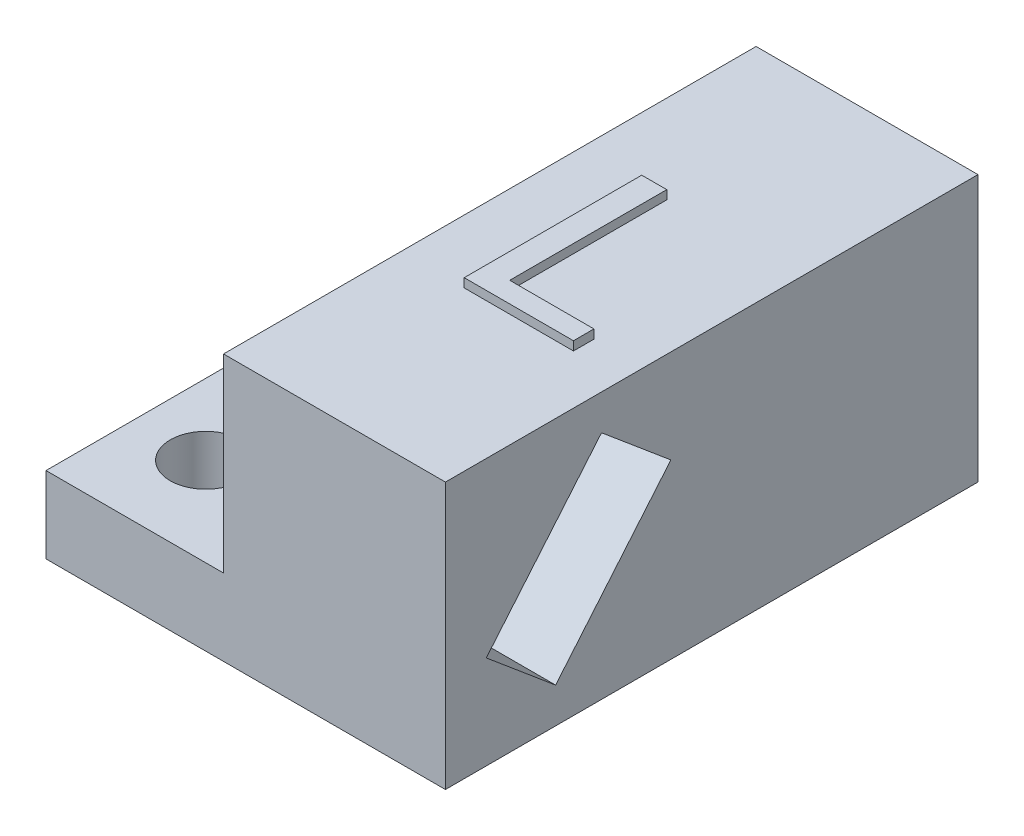
from build123d import *

# Parameters (mm, degrees)
SKETCH1_W           = 25
SKETCH1_H           = 60
BOSS_EXTRUDE1_DEPTH = 30
SKETCH2_W           = 60
SKETCH2_H           = 8.623813306
BOSS_EXTRUDE2_DEPTH = 20
SKETCH3_R           = 4
CUT_EXTRUDE1_DEPTH  = 9.623813306
CUT_EXTRUDE2_DEPTH  = 20
BOSS_EXTRUDE3_DEPTH = 1


with BuildPart() as part:
    # Sketch1 → Boss-Extrude1 (new body)
    with BuildSketch(Plane(origin=(0, 0, 0), x_dir=(1, 0, 0), z_dir=(0, 1, 0))):
        Rectangle(SKETCH1_W, SKETCH1_H)
    extrude(amount=BOSS_EXTRUDE1_DEPTH)

    # Sketch2 → Boss-Extrude2 (add)
    with BuildSketch(Plane.ZY.offset(12.5)):
        with Locations((0, 4.311906653)):
            Rectangle(SKETCH2_W, SKETCH2_H)
    extrude(amount=BOSS_EXTRUDE2_DEPTH)

    # Sketch3 → Cut-Extrude1 (cut, through all)
    with BuildSketch(Plane(origin=(0, 8.623813306, 0), x_dir=(1, 0, 0), z_dir=(0, 1, 0))):
        with Locations(Location((-24.5, 20, 0), (0, 0, 270))):  # turned: the seam where the file's is
            Circle(SKETCH3_R)
        with Locations(Location((-24.5, -20, 0), (0, 0, 270))):  # turned: the seam where the file's is
            Circle(SKETCH3_R)
    extrude(amount=-CUT_EXTRUDE1_DEPTH, mode=Mode.SUBTRACT)

    # Sketch4 → Cut-Extrude2 (cut)
    with BuildSketch(Plane(origin=(12.5, 0, 0), x_dir=(0, 0, -1), z_dir=(1, 0, 0))):
        Polygon((-17.585328198, 3.984734315), (-4.601018482, 19.458832066), (-12.414671802, 26.015265685), (-25.398981518, 10.541167934), align=None)
    extrude(amount=-CUT_EXTRUDE2_DEPTH, mode=Mode.SUBTRACT)

    # Sketch5 → Boss-Extrude3 (add)
    with BuildSketch(Plane(origin=(0, 30, 0), x_dir=(1, 0, 0), z_dir=(0, 1, 0))):
        Polygon((-5.384615385, -10), (-5.384615385, 10), (-2.564102564, 10), (-2.564102564, -7.692307692), (6.923076923, -7.692307692), (6.923076923, -10), align=None)
    extrude(amount=BOSS_EXTRUDE3_DEPTH)


solid = part.part
